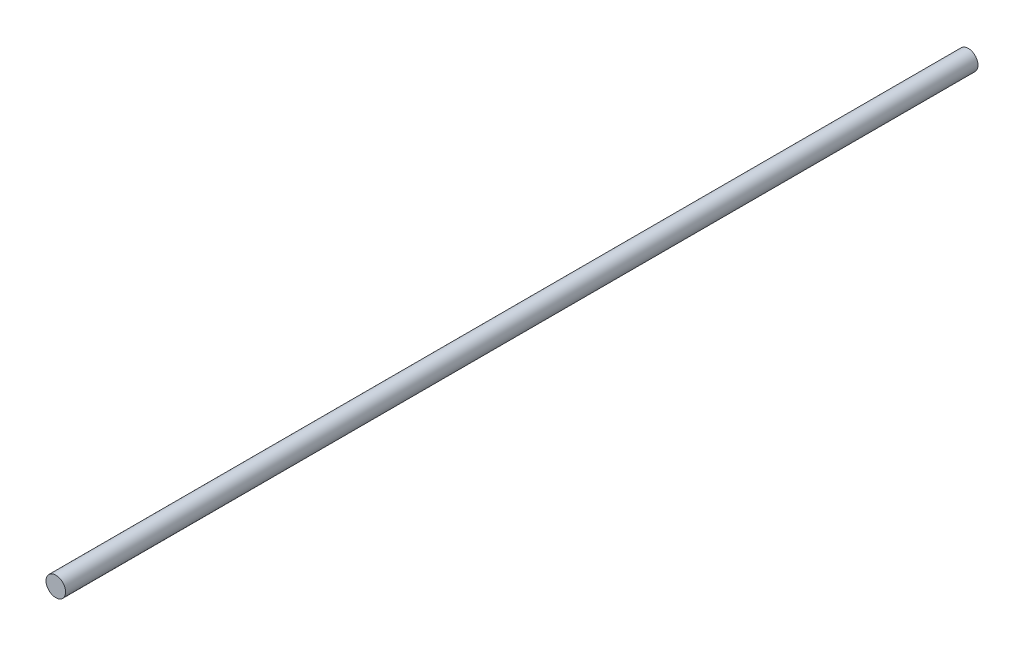
from build123d import *

# Parameters (mm, degrees)
ESQUISSE1_R             = 3
BOSS_EXTRU_1_DEPTH      = 251.072522
BOSS_EXTRU_1_DEPTH_BACK = 28.927478


with BuildPart() as part:
    # Esquisse1 → Boss.-Extru.1 (new body, two sides)
    with BuildSketch(Plane.XY) as boss_extru_1_sk:
        Circle(ESQUISSE1_R)
    extrude(amount=BOSS_EXTRU_1_DEPTH)
    extrude(boss_extru_1_sk.sketch, amount=-BOSS_EXTRU_1_DEPTH_BACK)


solid = part.part
